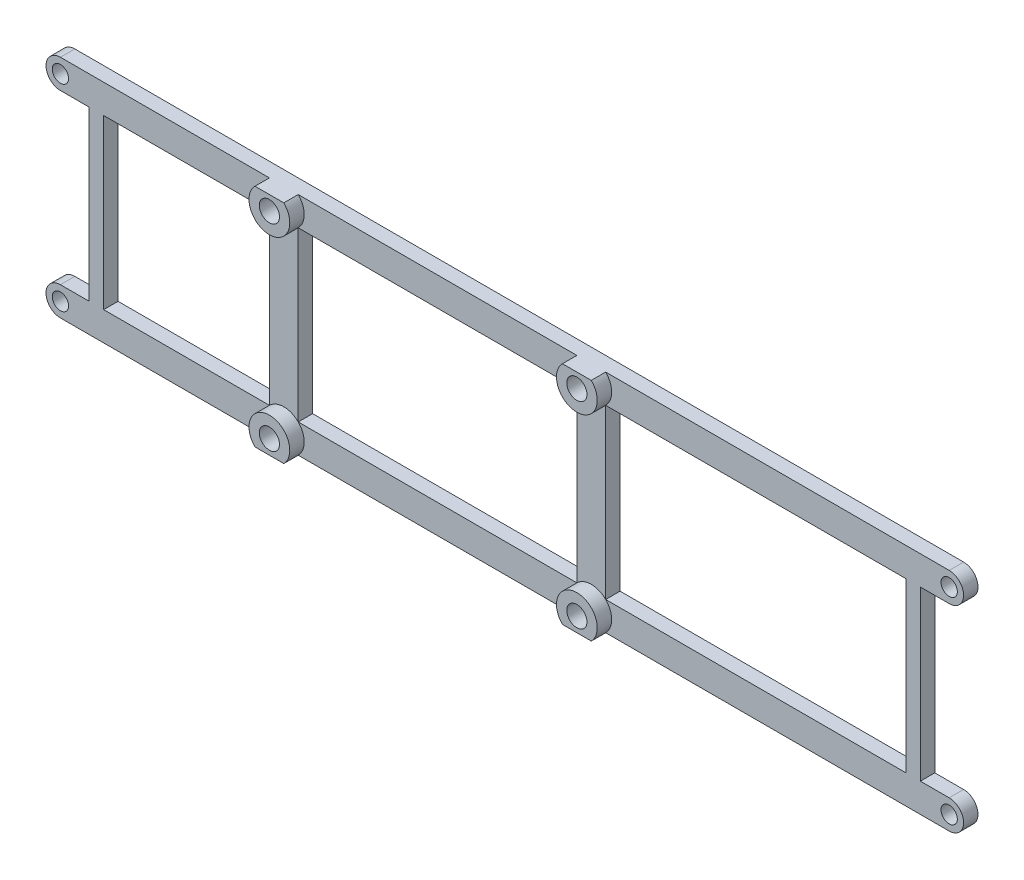
from build123d import *

# Parameters (mm, degrees)
ESBO_O1_R                = 1.7
ESBO_O1_W                = 58
ESBO_O1_H                = 35
RESSALTO_EXTRUS_O1_DEPTH = 3
ESBO_O2_R                = 2.1
RESSALTO_EXTRUS_O2_DEPTH = 3
ESBO_O3_W                = 3
ESBO_O3_H                = 35
EXTRUS_O_FINA1_DEPTH     = 3


with BuildPart() as part:
    # Esboço1 → Ressalto-extrusão1 (new body)
    with BuildSketch(Plane.XY):
        with BuildLine():
            Line((92.5, 23.5), (-92.5, 23.5))
            ThreePointArc((-92.5, 23.5), (-95.5, 20.5), (-92.5, 17.5))
            Line((-92.5, 17.5), (-49, 17.5))
            Line((-49, 17.5), (-49, -17.5))
            Line((-49, -17.5), (-92.5, -17.5))
            ThreePointArc((-92.5, -17.5), (-95.5, -20.5), (-92.5, -23.5))
            Line((-92.5, -23.5), (92.5, -23.5))
            ThreePointArc((92.5, -23.5), (95.5, -20.5), (92.5, -17.5))
            Line((92.5, -17.5), (21, -17.5))
            Line((21, -17.5), (21, 17.5))
            Line((21, 17.5), (92.5, 17.5))
            ThreePointArc((92.5, 17.5), (95.5, 20.5), (92.5, 23.5))
        make_face()
        with Locations((-92.5, 20.5)):
            Circle(ESBO_O1_R, mode=Mode.SUBTRACT)
        with Locations((92.5, 20.5)):
            Circle(ESBO_O1_R, mode=Mode.SUBTRACT)
        with Locations((18, 20.5)):
            Circle(ESBO_O1_R, mode=Mode.SUBTRACT)
        with Locations((-46, 20.5)):
            Circle(ESBO_O1_R, mode=Mode.SUBTRACT)
        with Locations((-46, -20.5)):
            Circle(ESBO_O1_R, mode=Mode.SUBTRACT)
        with Locations((18, -20.5)):
            Circle(ESBO_O1_R, mode=Mode.SUBTRACT)
        with Locations((92.5, -20.5)):
            Circle(ESBO_O1_R, mode=Mode.SUBTRACT)
        with Locations((-92.5, -20.5)):
            Circle(ESBO_O1_R, mode=Mode.SUBTRACT)
        with Locations((-14, 0)):
            Rectangle(ESBO_O1_W, ESBO_O1_H, mode=Mode.SUBTRACT)
    extrude(amount=RESSALTO_EXTRUS_O1_DEPTH)

    # Esboço2 → Ressalto-extrusão2 (add)
    with BuildSketch(Plane.XY.offset(3)):
        with BuildLine():
            Line((21, 23.5), (15, 23.5))
            ThreePointArc((15, 23.5), (18, 16.257359313), (21, 23.5))
        make_face()
        with Locations((18, 20.5)):
            Circle(ESBO_O2_R, mode=Mode.SUBTRACT)
        with BuildLine():
            Line((-49, -23.5), (-43, -23.5))
            ThreePointArc((-43, -23.5), (-46, -16.257359313), (-49, -23.5))
        make_face()
        with Locations((-46, -20.5)):
            Circle(ESBO_O2_R, mode=Mode.SUBTRACT)
        with BuildLine():
            Line((-43, 23.5), (-49, 23.5))
            ThreePointArc((-49, 23.5), (-46, 16.257359313), (-43, 23.5))
        make_face()
        with Locations((-46, 20.5)):
            Circle(ESBO_O2_R, mode=Mode.SUBTRACT)
        with BuildLine():
            Line((15, -23.5), (21, -23.5))
            ThreePointArc((21, -23.5), (18, -16.257359313), (15, -23.5))
        make_face()
        with Locations((18, -20.5)):
            Circle(ESBO_O2_R, mode=Mode.SUBTRACT)
    extrude(amount=RESSALTO_EXTRUS_O2_DEPTH)

    # Esboço3 → Extrusão-Fina1 (add, through all)
    with BuildSketch(Plane.XY.offset(3)):
        with Locations((-85, 0)):
            Rectangle(ESBO_O3_W, ESBO_O3_H)
        with Locations((85, 0)):
            Rectangle(ESBO_O3_W, ESBO_O3_H)
    extrude(amount=-EXTRUS_O_FINA1_DEPTH)


solid = part.part
